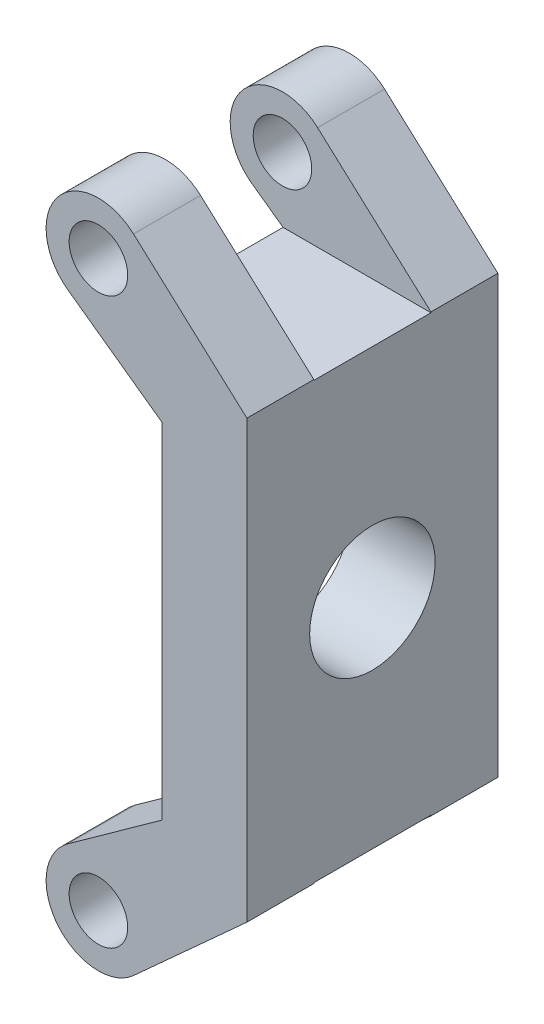
from build123d import *

# Parameters (mm, degrees)
SKETCH1_R           = 3.75
BOSS_EXTRUDE1_DEPTH = 12
SKETCH2_R           = 1.75
CUT_EXTRUDE1_DEPTH  = 16


with BuildPart() as part:
    # Sketch1 → Boss-Extrude1 (new body)
    with BuildSketch(Plane(origin=(0, 0, 0), x_dir=(0, 0, -1), z_dir=(1, 0, 0))):
        Polygon((-7.5, 20), (-3.5, 20), (-3.5, 13), (3.5, 13), (3.5, 20), (7.5, 20), (7.5, -20), (3.5, -20), (3.5, -13), (-3.5, -13), (-3.5, -20), (-7.5, -20), align=None)
        Circle(SKETCH1_R, mode=Mode.SUBTRACT)
    extrude(amount=BOSS_EXTRUDE1_DEPTH)

    # Sketch2 → Cut-Extrude1 (cut, through all)
    with BuildSketch(Plane.XY.offset(7.5)):
        with BuildLine():
            ThreePointArc((1.301959033, 14.335379208), (0.344469259, 15.447503856), (0, 16.874020182))
            Line((0, 16.874020182), (0, -16.874020197))
            ThreePointArc((0, -16.874020197), (0.344469255, -15.447503862), (1.301959033, -14.335379208))
            Line((1.301959033, -14.335379208), (6.934312509, -10.288517163))
            Line((6.934312509, -10.288517163), (6.934312509, 10.288517163))
            Line((6.934312509, 10.288517163), (1.301959033, 14.335379208))
        make_face()
        with BuildLine():
            ThreePointArc((0, 16.874020182), (0.915578291, 19.084421709), (3.125979818, 20))
            Line((3.125979818, 20), (0, 20))
            Line((0, 20), (0, 16.874020182))
        make_face()
        with Locations((3.125979818, 16.874020182)):
            Circle(SKETCH2_R)
        with BuildLine():
            ThreePointArc((3.125979818, 20), (4.251738736, 19.790253486), (5.226425655, 19.189161021))
            Line((5.226425655, 19.189161021), (8.613212827, 16.116448166))
            Line((8.613212827, 16.116448166), (12, 13.043735311))
            Line((12, 13.043735311), (12, 20))
            Line((12, 20), (3.125979818, 20))
        make_face()
        with BuildLine():
            Line((12, -20), (12, -13.043735311))
            Line((12, -13.043735311), (8.613212827, -16.116448166))
            Line((8.613212827, -16.116448166), (5.226425655, -19.189161021))
            ThreePointArc((5.226425655, -19.189161021), (4.251738736, -19.790253486), (3.125979818, -20))
            Line((3.125979818, -20), (12, -20))
        make_face()
        with BuildLine():
            ThreePointArc((3.125979818, -20), (0.915578296, -19.084421715), (0, -16.874020197))
            Line((0, -16.874020197), (0, -20))
            Line((0, -20), (3.125979818, -20))
        make_face()
        with Locations((3.125979818, -16.874020182)):
            Circle(SKETCH2_R)
    extrude(amount=-CUT_EXTRUDE1_DEPTH, mode=Mode.SUBTRACT)


solid = part.part
